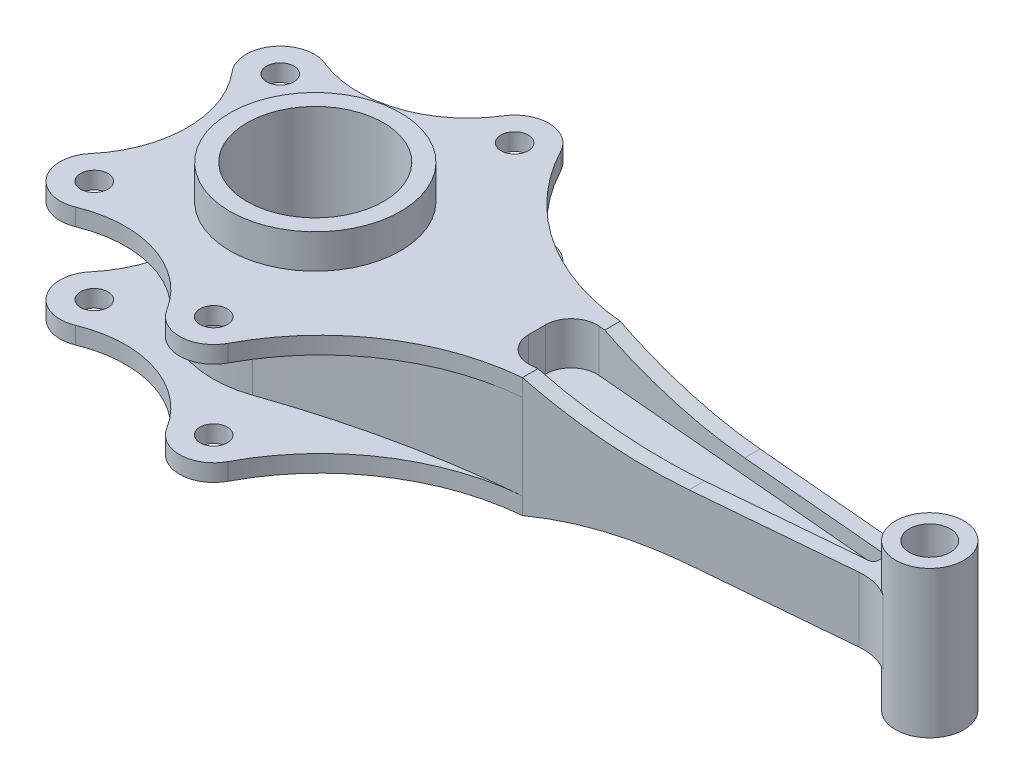
from build123d import *

# Parameters (mm, degrees)
SKETCH1_R           = 25
SKETCH1_R_2         = 10
SKETCH1_R_3         = 4
SKETCH1_R_4         = 20
BOSS_EXTRUDE1_DEPTH = 17.5
SKETCH1_4_R         = 25
SKETCH1_4_R_2       = 20
BOSS_EXTRUDE2_DEPTH = 27.5
SKETCH2_R           = 20
CUT_EXTRUDE1_DEPTH  = 12.5
CUT_EXTRUDE2_DEPTH  = 55.083893922
SKETCH1_5_R         = 10
SKETCH1_5_R_2       = 6
BOSS_EXTRUDE3_DEPTH = 21.5
FILLET3_R           = 15
CUT_EXTRUDE3_DEPTH  = 12.5
FILLET1_R           = 7.5
FILLET2_R           = 1.5


with BuildPart() as part:
    # Sketch1 → Boss-Extrude1 (new body, symmetric)
    with BuildSketch(Plane(origin=(0, 0, 0), x_dir=(1, 0, 0), z_dir=(0, 1, 0))):
        with BuildLine():
            ThreePointArc((23.169245136, -48.74831039), (44.696355929, -24.926018406), (75, -14.314362055))
            Line((75, -14.314362055), (171.881275704, -5.838348723))
            ThreePointArc((171.881275704, -5.838348723), (170, 0), (171.881275704, 5.838348723))
            Line((171.881275704, 5.838348723), (75, 14.314362055))
            ThreePointArc((75, 14.314362055), (44.696355929, 24.926018406), (23.169245136, 48.74831039))
            ThreePointArc((23.169245136, 48.74831039), (24.030815541, 46.486476164), (24.323725422, 44.083893922))
            ThreePointArc((24.323725422, 44.083893922), (11.593351964, 34.463859578), (5.814713266, 49.337151209))
            ThreePointArc((5.814713266, 49.337151209), (-11.588137289, 35.664619361), (-33.70385172, 36.496791078))
            ThreePointArc((-33.70385172, 36.496791078), (-29.194535449, 32.814838368), (-27.5, 27.2453448))
            ThreePointArc((-27.5, 27.2453448), (-34.054404214, 17.857700278), (-45.125573936, 20.776139119))
            ThreePointArc((-45.125573936, 20.776139119), (-37.5, 0), (-45.125573936, -20.776139119))
            ThreePointArc((-45.125573936, -20.776139119), (-34.054404214, -17.857700278), (-27.5, -27.2453448))
            ThreePointArc((-27.5, -27.2453448), (-29.194535449, -32.814838368), (-33.70385172, -36.496791078))
            ThreePointArc((-33.70385172, -36.496791078), (-11.588137289, -35.664619361), (5.814713266, -49.337151209))
            ThreePointArc((5.814713266, -49.337151209), (11.593351964, -34.463859578), (24.323725422, -44.083893922))
            ThreePointArc((24.323725422, -44.083893922), (24.030815541, -46.486476164), (23.169245136, -48.74831039))
        make_face()
        Circle(SKETCH1_R, mode=Mode.SUBTRACT)
        with Locations((14.323725422, 44.083893922)):
            Circle(SKETCH1_R_2)
        with Locations((14.323725422, 44.083893922)):
            Circle(SKETCH1_R_3, mode=Mode.SUBTRACT)
        with Locations((-37.5, 27.2453448)):
            Circle(SKETCH1_R_2)
        with Locations((-37.5, 27.2453448)):
            Circle(SKETCH1_R_3, mode=Mode.SUBTRACT)
        with Locations((-37.5, -27.2453448)):
            Circle(SKETCH1_R_2)
        with Locations((-37.5, -27.2453448)):
            Circle(SKETCH1_R_3, mode=Mode.SUBTRACT)
        with Locations((14.323725422, -44.083893922)):
            Circle(SKETCH1_R_2)
        with Locations((14.323725422, -44.083893922)):
            Circle(SKETCH1_R_3, mode=Mode.SUBTRACT)
        Circle(SKETCH1_R)
        Circle(SKETCH1_R_4, mode=Mode.SUBTRACT)
    extrude(amount=BOSS_EXTRUDE1_DEPTH, both=True)

    # Sketch1_4 → Boss-Extrude2 (add, symmetric)
    with BuildSketch(Plane(origin=(0, 0, 0), x_dir=(1, 0, 0), z_dir=(0, 1, 0))):
        Circle(SKETCH1_4_R)
        Circle(SKETCH1_4_R_2, mode=Mode.SUBTRACT)
    extrude(amount=BOSS_EXTRUDE2_DEPTH, both=True)

    # Sketch2 → Cut-Extrude1 (cut, symmetric)
    with BuildSketch(Plane(origin=(0, 0, 0), x_dir=(1, 0, 0), z_dir=(0, 1, 0))):
        Circle(SKETCH2_R)
        with BuildLine():
            ThreePointArc((9.905954739, 28.31734558), (-30, 0), (9.905954739, -28.31734558))
            ThreePointArc((9.905954739, -28.31734558), (42.01613595, -19.285159783), (75, -14.314362055))
            ThreePointArc((75, -14.314362055), (44.696355929, -24.926018406), (23.169245136, -48.74831039))
            ThreePointArc((23.169245136, -48.74831039), (14.662831175, -54.078142632), (5.814713266, -49.337151209))
            ThreePointArc((5.814713266, -49.337151209), (-11.588137289, -35.664619361), (-33.70385172, -36.496791078))
            ThreePointArc((-33.70385172, -36.496791078), (-45.590169944, -33.123197323), (-45.125573936, -20.776139119))
            ThreePointArc((-45.125573936, -20.776139119), (-37.5, 0), (-45.125573936, 20.776139119))
            ThreePointArc((-45.125573936, 20.776139119), (-45.590169944, 33.123197323), (-33.70385172, 36.496791078))
            ThreePointArc((-33.70385172, 36.496791078), (-11.588137289, 35.664619361), (5.814713266, 49.337151209))
            ThreePointArc((5.814713266, 49.337151209), (14.662831175, 54.078142632), (23.169245136, 48.74831039))
            ThreePointArc((23.169245136, 48.74831039), (44.696355929, 24.926018406), (75, 14.314362055))
            ThreePointArc((75, 14.314362055), (42.01613595, 19.285159783), (9.905954739, 28.31734558))
        make_face()
    extrude(amount=CUT_EXTRUDE1_DEPTH, both=True, mode=Mode.SUBTRACT)

    # Sketch3 → Cut-Extrude2 (cut, symmetric)
    with BuildSketch(Plane.XY):
        with BuildLine():
            Line((171.881275704, 17.5), (171.881275704, 9.5))
            Line((171.881275704, 9.5), (119.899888641, 9.5))
            ThreePointArc((119.899888641, 9.5), (97.096380139, 11.515625954), (75, 17.5))
            Line((75, 17.5), (119.899888641, 17.5))
            Line((119.899888641, 17.5), (171.881275704, 17.5))
        make_face()
    cut_extrude2 = extrude(amount=CUT_EXTRUDE2_DEPTH, both=True, mode=Mode.SUBTRACT)

    # Mirror1: Cut-Extrude2 across plane
    add(cut_extrude2.mirror(Plane.ZX), mode=Mode.SUBTRACT)

    # Sketch1_5 → Boss-Extrude3 (add, symmetric)
    with BuildSketch(Plane(origin=(0, 0, 0), x_dir=(1, 0, 0), z_dir=(0, 1, 0))):
        with Locations((180, 0)):
            Circle(SKETCH1_5_R)
        with Locations((180, 0)):
            Circle(SKETCH1_5_R_2, mode=Mode.SUBTRACT)
    extrude(amount=BOSS_EXTRUDE3_DEPTH, both=True)

    # Fillet3
    fillet3_edges = [part.edges().sort_by_distance(p)[0] for p in [
        (171.881275704, 0, -5.838348723),
        (171.881275704, 0, 5.838348723),
    ]]
    fillet(fillet3_edges, radius=FILLET3_R)

    # Sketch4 → Cut-Extrude3 (cut)
    with BuildSketch(Plane(origin=(0, 17.5, 0), x_dir=(1, 0, 0), z_dir=(0, 1, 0))):
        with BuildLine():
            Line((65, 10.672059421), (65, -10.672059421))
            Line((65, -10.672059421), (119.507687799, -5.903254663))
            Line((119.507687799, -5.903254663), (165.620941154, -1.868867757))
            ThreePointArc((165.620941154, -1.868867757), (165.5, 0), (165.620941154, 1.868867757))
            Line((165.620941154, 1.868867757), (119.507687799, 5.903254663))
            Line((119.507687799, 5.903254663), (65, 10.672059421))
        make_face()
    cut_extrude3 = extrude(amount=-CUT_EXTRUDE3_DEPTH, mode=Mode.SUBTRACT)

    # Mirror2: Cut-Extrude3 across plane
    add(cut_extrude3.mirror(Plane.ZX), mode=Mode.SUBTRACT)

    # Fillet1
    fillet1_edges = [part.edges().sort_by_distance(p)[0] for p in [
        (65, 11.25, -10.672059421),
        (65, 11.25, 10.672059421),
        (65, -11.25, -10.672059421),
        (65, -11.25, 10.672059421),
    ]]
    fillet(fillet1_edges, radius=FILLET1_R)

    # Fillet2
    fillet2_edges = [part.edges().sort_by_distance(p)[0] for p in [
        (165.620941154, 7.25, -1.868867757),
        (165.620941154, 7.25, 1.868867757),
        (165.620941154, -7.25, 1.868867757),
        (165.620941154, -7.25, -1.868867757),
    ]]
    fillet(fillet2_edges, radius=FILLET2_R)


solid = part.part
